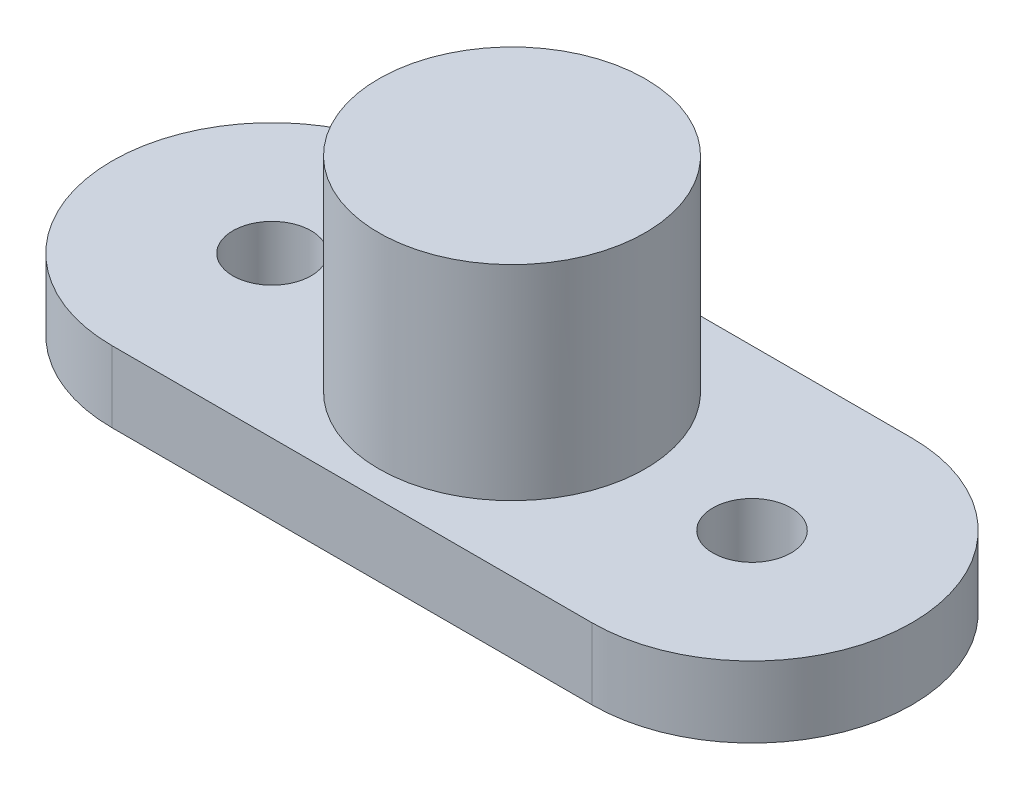
from build123d import *

# Parameters (mm, degrees)
SKETCH1_R           = 1.1
SKETCH1_R_2         = 3.75
BOSS_EXTRUDE3_DEPTH = 2
SKETCH3_R           = 3.75
BOSS_EXTRUDE4_DEPTH = 7.75


with BuildPart() as part:
    # Sketch1 → Boss-Extrude3 (new body)
    with BuildSketch(Plane(origin=(0, 0, 0), x_dir=(1, 0, 0), z_dir=(0, 1, 0))):
        with BuildLine():
            Line((-6.75, 4.499502967), (6.75, 4.499502967))
            ThreePointArc((6.75, 4.499502967), (11.249502967, 0), (6.75, -4.499502967))
            Line((6.75, -4.499502967), (-6.75, -4.499502967))
            ThreePointArc((-6.75, -4.499502967), (-11.249502967, 0), (-6.75, 4.499502967))
        make_face()
        with Locations((-6.75, 0)):
            Circle(SKETCH1_R, mode=Mode.SUBTRACT)
        with Locations((6.75, 0)):
            Circle(SKETCH1_R, mode=Mode.SUBTRACT)
        Circle(SKETCH1_R_2, mode=Mode.SUBTRACT)
    extrude(amount=BOSS_EXTRUDE3_DEPTH)

    # Sketch3 → Boss-Extrude4 (add)
    with BuildSketch(Plane.XZ):
        Circle(SKETCH3_R)
    extrude(amount=-BOSS_EXTRUDE4_DEPTH)


solid = part.part
